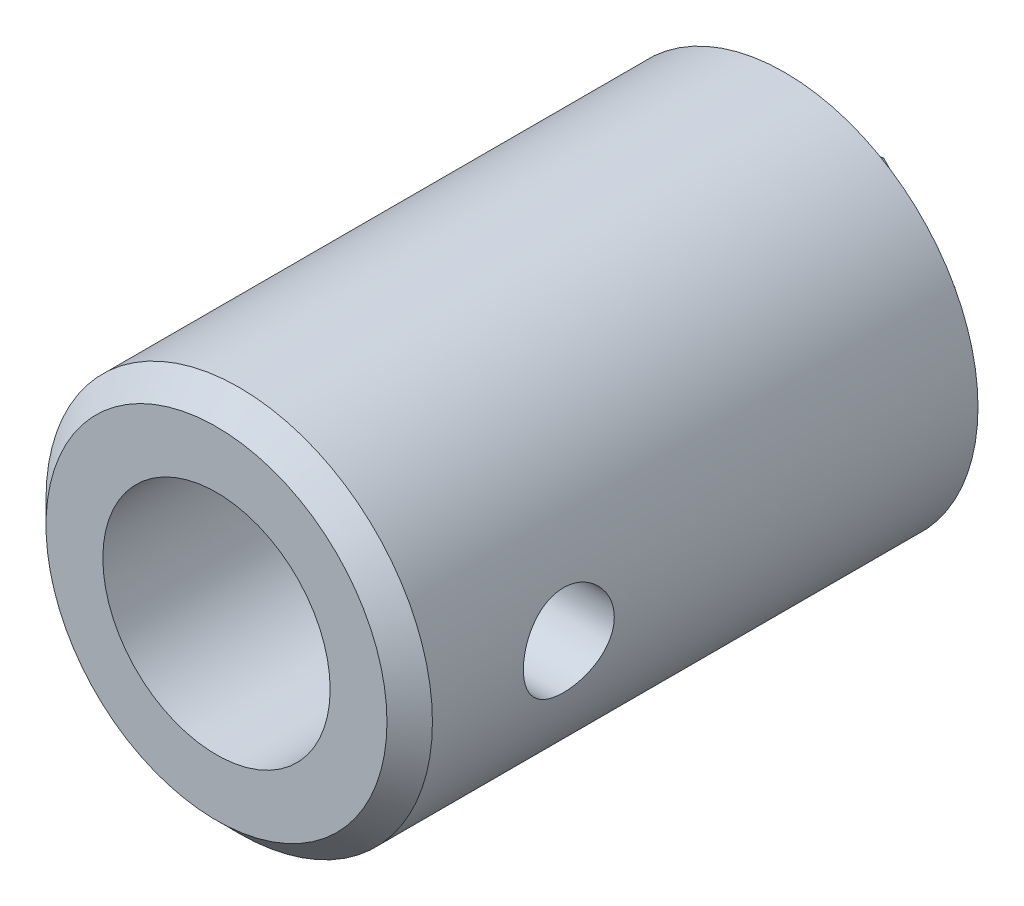
from build123d import *

# Parameters (mm, degrees)
SKETCH1_R           = 8.5
SKETCH1_R_2         = 2
BOSS_EXTRUDE1_DEPTH = 5
SKETCH2_R           = 8.5
SKETCH2_R_2         = 5
BOSS_EXTRUDE2_DEPTH = 20
SKETCH3_R           = 2
BOSS_EXTRUDE3_DEPTH = 3
CHAMFER1_SIZE       = 1
CUT_EXTRUDE1_REACH  = 19
SKETCH4_R           = 2


with BuildPart() as part:
    # Sketch1 → Boss-Extrude1 (new body)
    with BuildSketch(Plane.XY):
        Circle(SKETCH1_R)
        Circle(SKETCH1_R_2, mode=Mode.SUBTRACT)
    extrude(amount=BOSS_EXTRUDE1_DEPTH)

    # Sketch2 → Boss-Extrude2 (add)
    with BuildSketch(Plane.XY.offset(5)):
        Circle(SKETCH2_R)
        Circle(SKETCH2_R_2, mode=Mode.SUBTRACT)
    extrude(amount=BOSS_EXTRUDE2_DEPTH)

    # Sketch3 → Boss-Extrude3 (add)
    with BuildSketch(Plane(origin=(0, 0, 0), x_dir=(-1, 0, 0), z_dir=(0, 0, -1))):
        Polygon((-4.500595024, 1.03825708), (-3.149454519, -3.378501083), (1.351140505, -4.416758163), (4.500595024, -1.03825708), (3.149454519, 3.378501083), (-1.351140505, 4.416758163), align=None)
        Circle(SKETCH3_R, mode=Mode.SUBTRACT)
    extrude(amount=BOSS_EXTRUDE3_DEPTH)

    # Chamfer1
    chamfer1_edges = [part.edges().sort_by_distance(p)[0] for p in [
        (-8.5, 0, 25),
    ]]
    chamfer(chamfer1_edges, length=CHAMFER1_SIZE)

    # Sketch4 → Cut-Extrude1 (cut, up to next)
    with BuildSketch(Plane(origin=(8.5, 0, 0), x_dir=(0, 0, -1), z_dir=(1, 0, 0)), mode=Mode.PRIVATE) as cut_extrude1_sk1:
        with Locations((-18, 0)):
            Circle(SKETCH4_R)
    cut_extrude1_tool1 = extrude(cut_extrude1_sk1.sketch, amount=-CUT_EXTRUDE1_REACH, mode=Mode.PRIVATE) & part.part
    add(cut_extrude1_tool1.solids().sort_by_distance((8.5, 0, 18))[0], mode=Mode.SUBTRACT)


solid = part.part
